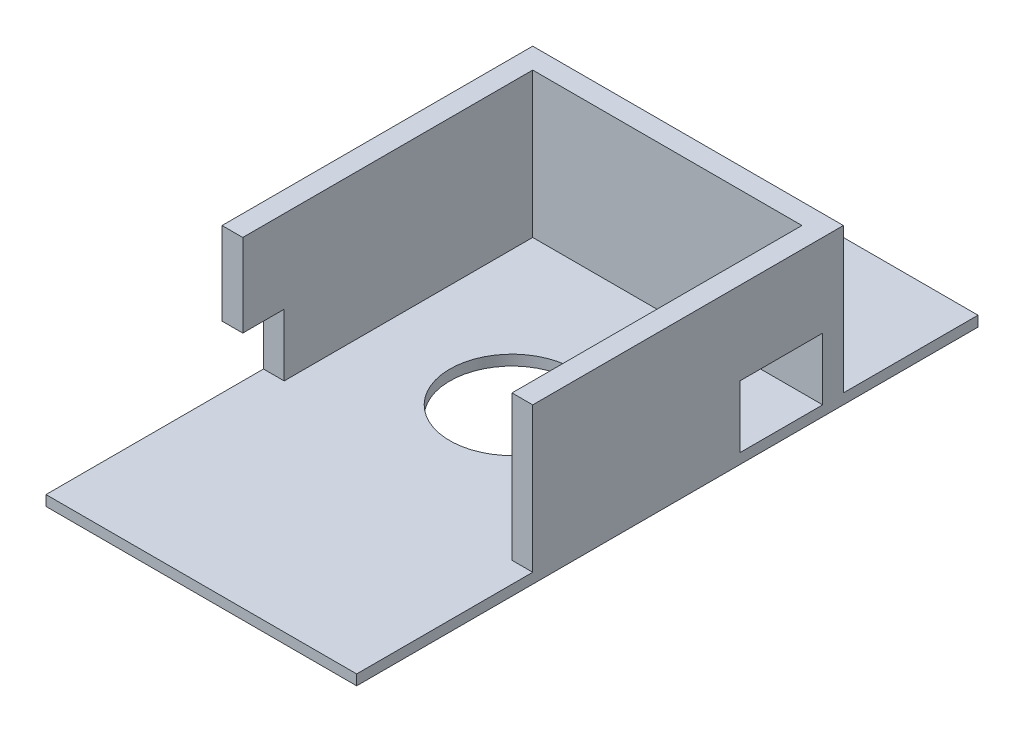
from build123d import *

# Parameters (mm, degrees)
SKETCH3_W           = 75
SKETCH3_H           = 85
BOSS_EXTRUDE1_DEPTH = 35
SKETCH4_W           = 65
SKETCH4_H           = 75
CUT_EXTRUDE1_DEPTH  = 40
SKETCH8_W           = 75
SKETCH8_H           = 150
BOSS_EXTRUDE2_DEPTH = 2.5
SKETCH9_R           = 15
CUT_EXTRUDE4_DEPTH  = 15
SKETCH10_W          = 75
SKETCH10_H          = 33.016749553
CUT_EXTRUDE5_DEPTH  = 10
SKETCH16_W          = 20
SKETCH16_H          = 15
CUT_EXTRUDE6_DEPTH  = 10
SKETCH17_W          = 10
SKETCH17_H          = 1.983250447
CUT_EXTRUDE7_DEPTH  = 66
SKETCH19_W          = 20
SKETCH19_H          = 15
CUT_EXTRUDE8_DEPTH  = 10


with BuildPart() as part:
    # Sketch3 → Boss-Extrude1 (new body)
    with BuildSketch(Plane(origin=(0, 0, 0), x_dir=(1, 0, 0), z_dir=(0, 1, 0))):
        with Locations((4.321862348, -20.010121457)):
            Rectangle(SKETCH3_W, SKETCH3_H)
    extrude(amount=BOSS_EXTRUDE1_DEPTH)

    # Sketch4 → Cut-Extrude1 (cut)
    with BuildSketch(Plane(origin=(0, 35, 0), x_dir=(1, 0, 0), z_dir=(0, 1, 0))):
        with Locations((4.321862348, -20.010121457)):
            Rectangle(SKETCH4_W, SKETCH4_H)
    extrude(amount=-CUT_EXTRUDE1_DEPTH, mode=Mode.SUBTRACT)

    # Sketch8 → Boss-Extrude2 (add)
    with BuildSketch(Plane.XZ):
        with Locations((4.321862348, 20.010121457)):
            Rectangle(SKETCH8_W, SKETCH8_H)
    extrude(amount=BOSS_EXTRUDE2_DEPTH)

    # Sketch9 → Cut-Extrude4 (cut)
    with BuildSketch(Plane.XZ.offset(2.5)):
        with Locations((4.321862348, 20.010121457)):
            Circle(SKETCH9_R)
    extrude(amount=-CUT_EXTRUDE4_DEPTH, mode=Mode.SUBTRACT)

    # Sketch10 → Cut-Extrude5 (cut)
    with BuildSketch(Plane.XY.offset(62.510121457)):
        with Locations((4.321862348, 18.491625224)):
            Rectangle(SKETCH10_W, SKETCH10_H)
    extrude(amount=-CUT_EXTRUDE5_DEPTH, mode=Mode.SUBTRACT)

    # Sketch16 → Cut-Extrude6 (cut)
    with BuildSketch(Plane.ZY.offset(33.178137652)):
        with Locations((52.510121457, 7.5)):
            Rectangle(SKETCH16_W, SKETCH16_H)
    extrude(amount=-CUT_EXTRUDE6_DEPTH, mode=Mode.SUBTRACT)

    # Sketch17 → Cut-Extrude7 (cut, through all)
    with BuildSketch(Plane.ZY.offset(23.178137652)):
        with Locations((57.510121457, 0.991625224)):
            Rectangle(SKETCH17_W, SKETCH17_H)
    extrude(amount=-CUT_EXTRUDE7_DEPTH, mode=Mode.SUBTRACT)

    # Sketch19 → Cut-Extrude8 (cut)
    with BuildSketch(Plane(origin=(41.821862348, 0, 0), x_dir=(0, 0, -1), z_dir=(1, 0, 0))):
        with Locations((7.489878543, 7.5)):
            Rectangle(SKETCH19_W, SKETCH19_H)
    extrude(amount=-CUT_EXTRUDE8_DEPTH, mode=Mode.SUBTRACT)


solid = part.part
